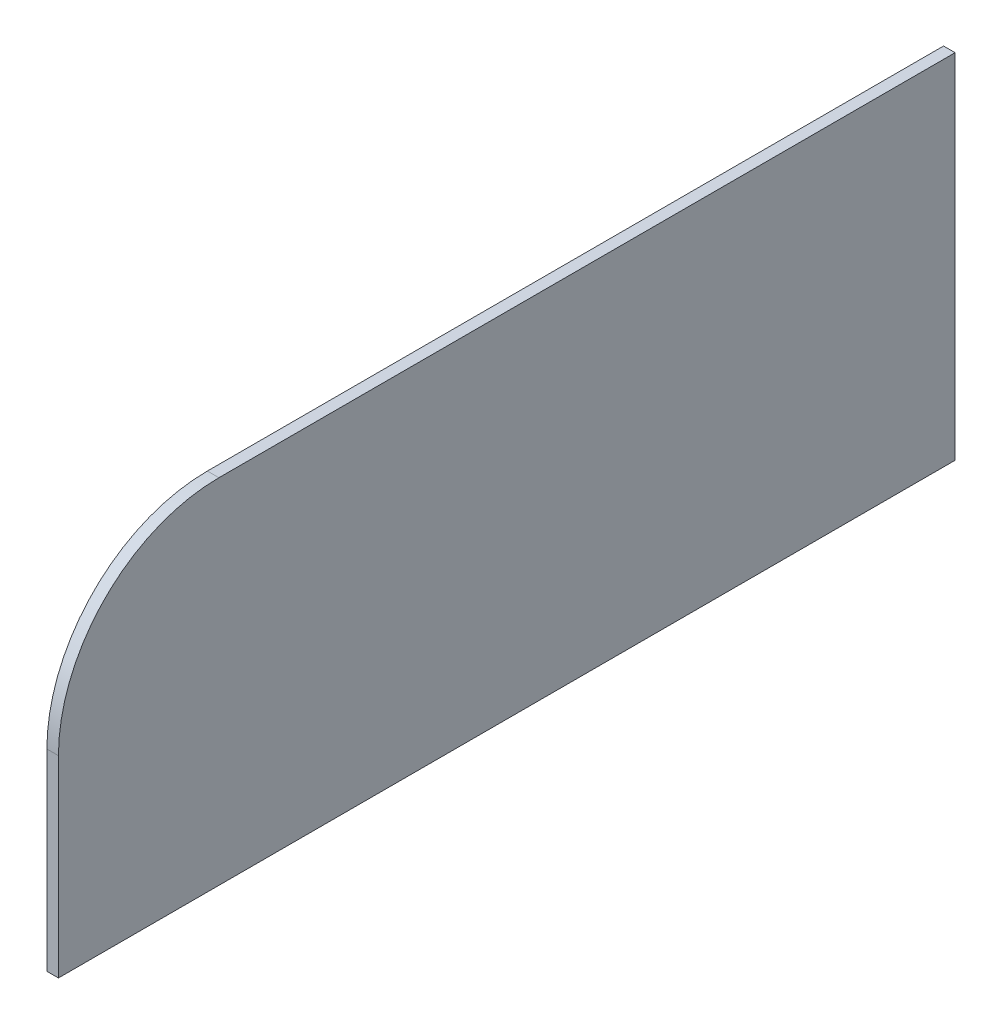
from build123d import *

# Parameters (mm, degrees)
BOSS_EXTRUDE1_DEPTH = 18


with BuildPart() as part:
    # Sketch1 → Boss-Extrude1 (new body)
    with BuildSketch(Plane(origin=(0, 0, 0), x_dir=(0, 0, -1), z_dir=(1, 0, 0))):
        with BuildLine():
            Line((1129.392066811, -492.219556499), (-267.607933189, -492.219556499))
            Line((-267.607933189, -492.219556499), (-267.607933189, -192.219556499))
            ThreePointArc((-267.607933189, -192.219556499), (-194.384628485, -15.442861202), (-17.607933189, 57.780443501))
            Line((-17.607933189, 57.780443501), (1129.392066811, 57.780443501))
            Line((1129.392066811, 57.780443501), (1129.392066811, -492.219556499))
        make_face()
    extrude(amount=BOSS_EXTRUDE1_DEPTH)


solid = part.part
